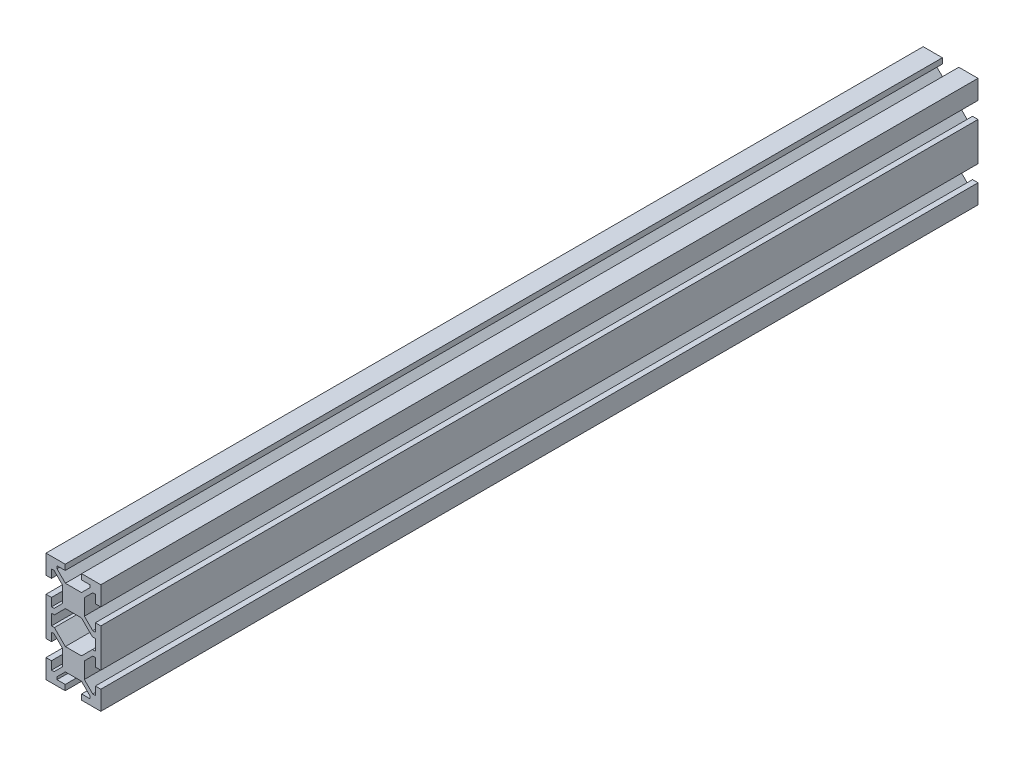
from build123d import *

# Parameters (mm, degrees)
BOSS_EXTRUDE1_DEPTH = 160


with BuildPart() as part:
    # Sketch1 → Boss-Extrude1 (new body, symmetric)
    with BuildSketch(Plane.XY):
        Polygon((-6, -17.060660172), (-2.939339828, -14), (2.939339828, -14), (6, -17.060660172), (6, -18), (3, -18), (3, -20), (10, -20), (10, -13), (8, -13), (8, -16), (7.060660172, -16), (4, -12.939339828), (4, -7.060660172), (7.060660172, -4), (8, -4), (8, -7), (10, -7), (10, 7), (8, 7), (8, 4), (7.060660172, 4), (4, 7.060660172), (4, 12.939339828), (7.060660172, 16), (8, 16), (8, 13), (10, 13), (10, 20), (3, 20), (3, 18), (6, 18), (6, 17.060660172), (2.939339828, 14), (-2.939339828, 14), (-6, 17.060660172), (-6, 18), (-3, 18), (-3, 20), (-10, 20), (-10, 13), (-8, 13), (-8, 16), (-7.060660172, 16), (-4, 12.939339828), (-4, 7.060660172), (-7.060660172, 4), (-8, 4), (-8, 7), (-10, 7), (-10, -7), (-8, -7), (-8, -4), (-7.060660172, -4), (-4, -7.060660172), (-4, -12.939339828), (-7.060660172, -16), (-8, -16), (-8, -13), (-10, -13), (-10, -20), (-3, -20), (-3, -18), (-6, -18), align=None)
        Polygon((-6.939339828, -2), (-8, -2), (-8, 2), (-6.939339828, 2), (-2.939339828, 6), (2.939339828, 6), (6.939339828, 2), (8, 2), (8, -2), (6.939339828, -2), (2.939339828, -6), (-2.939339828, -6), align=None, mode=Mode.SUBTRACT)
    extrude(amount=BOSS_EXTRUDE1_DEPTH, both=True)


solid = part.part
